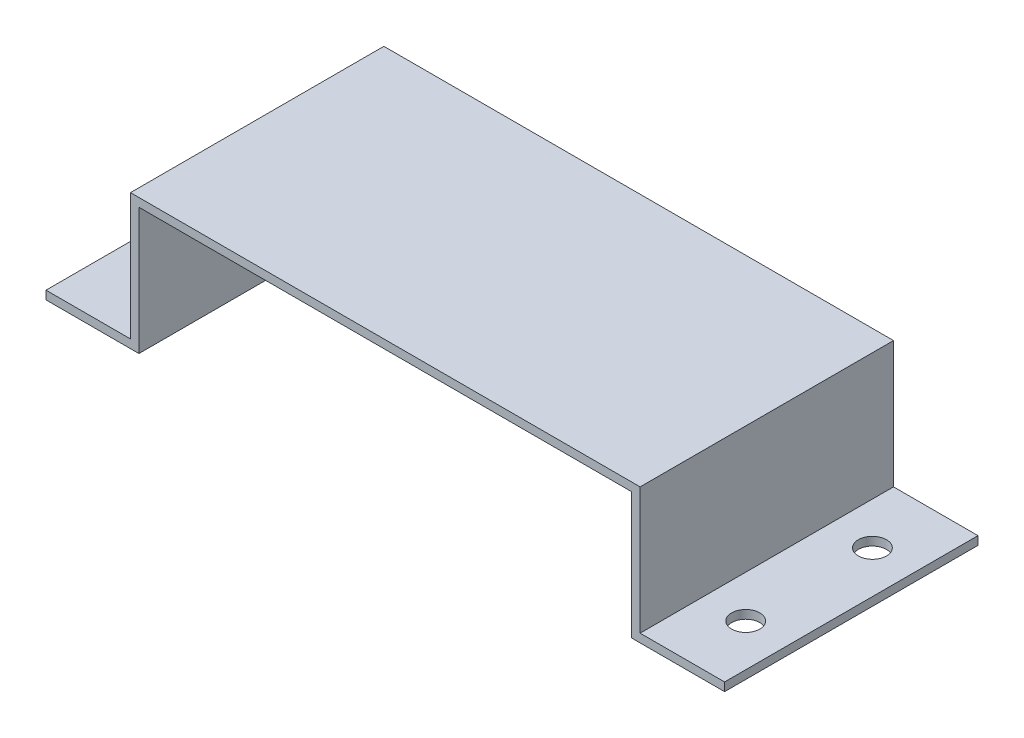
from build123d import *

# Parameters (mm, degrees)
BOSS_EXTRUDE1_DEPTH = 90
SKETCH2_R           = 5
CUT_EXTRUDE1_DEPTH  = 90


with BuildPart() as part:
    # Sketch1 → Boss-Extrude1 (new body)
    with BuildSketch(Plane.XY):
        Polygon((-51.967349513, 26.424347916), (129.032650487, 26.424347916), (129.032650487, -18.575652084), (159.032650487, -18.575652084), (159.032650487, -21.575652084), (129.032650487, -21.575652084), (126.032650487, -21.575652084), (126.032650487, 23.424347916), (-48.967349513, 23.424347916), (-48.967349513, -21.575652084), (-51.967349513, -21.575652084), (-81.967349513, -21.575652084), (-81.967349513, -18.575652084), (-51.967349513, -18.575652084), align=None)
    extrude(amount=BOSS_EXTRUDE1_DEPTH)

    # Sketch2 → Cut-Extrude1 (cut)
    with BuildSketch(Plane(origin=(0, -18.575652084, 0), x_dir=(1, 0, 0), z_dir=(0, 1, 0))):
        with Locations((144.032650487, -22.5)):
            Circle(SKETCH2_R)
        with Locations((144.032650487, -67.5)):
            Circle(SKETCH2_R)
        with Locations((-66.967349513, -67.5)):
            Circle(SKETCH2_R)
        with Locations((-66.967349513, -22.5)):
            Circle(SKETCH2_R)
    extrude(amount=-CUT_EXTRUDE1_DEPTH, mode=Mode.SUBTRACT)


solid = part.part
